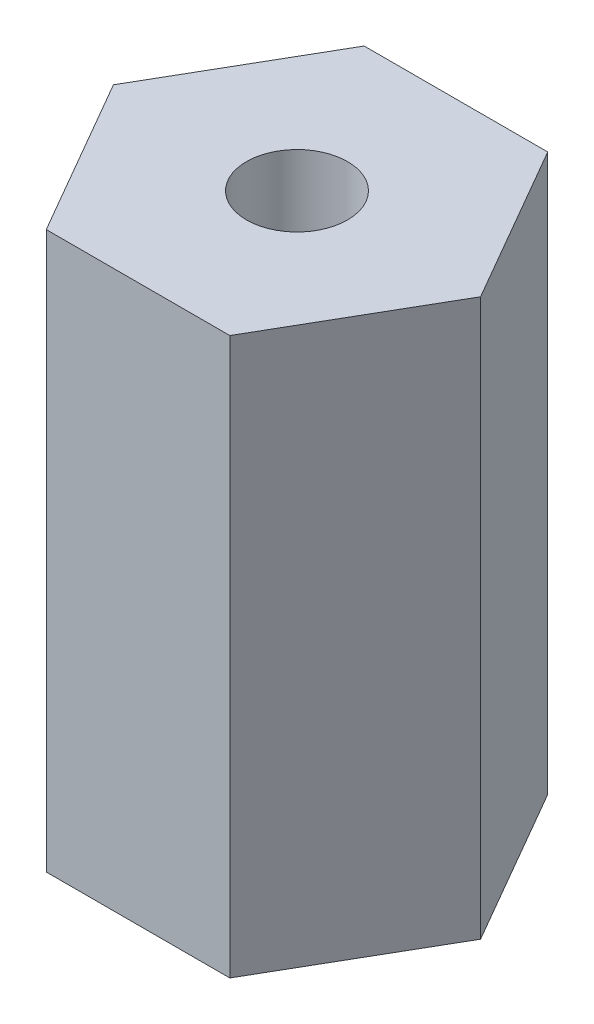
from build123d import *

# Parameters (mm, degrees)
BOSS_EXTRUDE1_DEPTH        = 22.225
F_10_32_TAPPED_HOLE1_D     = 4.0386
F_10_32_TAPPED_HOLE1_DEPTH = 13.6144
F_10_32_TAPPED_HOLE1_TIP   = 1.213317848


with BuildPart() as part:
    # Sketch1 → Boss-Extrude1 (new body)
    with BuildSketch(Plane(origin=(0, 0, 0), x_dir=(1, 0, 0), z_dir=(0, 1, 0))):
        Polygon((7.332348419, 0), (3.666174209, 6.35), (-3.666174209, 6.35), (-7.332348419, 0), (-3.666174209, -6.35), (3.666174209, -6.35), align=None)
    extrude(amount=BOSS_EXTRUDE1_DEPTH)

    # #10-32 Tapped Hole1
    with Locations(Plane(origin=(0, 22.225, 0), x_dir=(1, 0, 0), z_dir=(0, 1, 0))):
        with Locations((0, 0)):
            Hole(F_10_32_TAPPED_HOLE1_D / 2, depth=F_10_32_TAPPED_HOLE1_DEPTH)
            with Locations((0, 0, -(F_10_32_TAPPED_HOLE1_DEPTH + F_10_32_TAPPED_HOLE1_TIP / 2))):  # 118° drill point
                Cone(0, F_10_32_TAPPED_HOLE1_D / 2, F_10_32_TAPPED_HOLE1_TIP, mode=Mode.SUBTRACT)


solid = part.part
